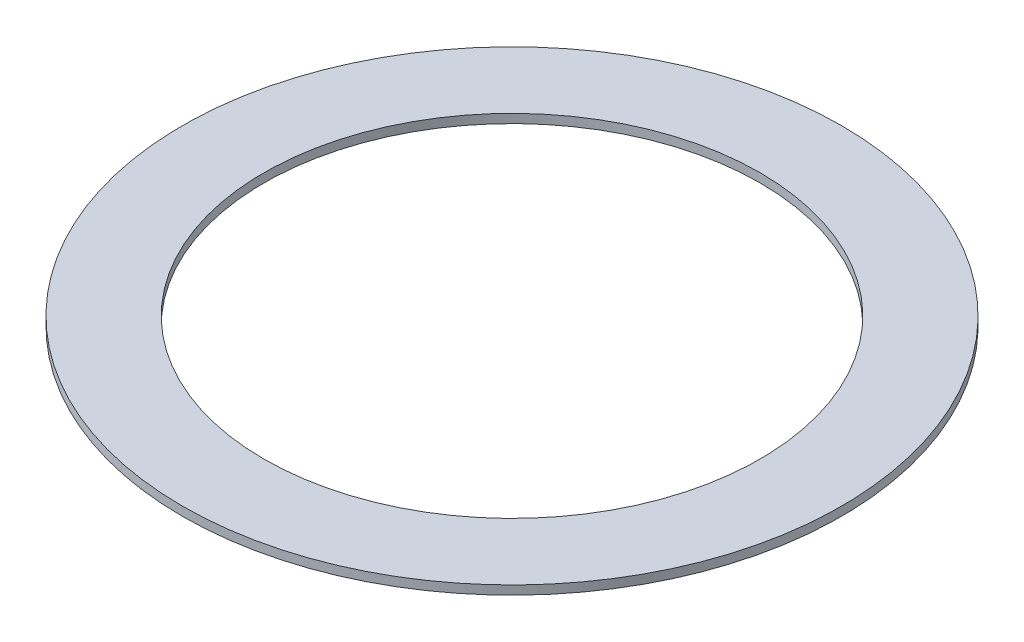
from build123d import *

# Parameters (mm, degrees)
SKETCH1_R           = 118.11
SKETCH1_R_2         = 88.9
BOSS_EXTRUDE1_DEPTH = 3.175


with BuildPart() as part:
    # Sketch1 → Boss-Extrude1 (new body)
    with BuildSketch(Plane(origin=(0, 0, 0), x_dir=(1, 0, 0), z_dir=(0, 1, 0))):
        Circle(SKETCH1_R)
        Circle(SKETCH1_R_2, mode=Mode.SUBTRACT)
    extrude(amount=BOSS_EXTRUDE1_DEPTH)


solid = part.part
